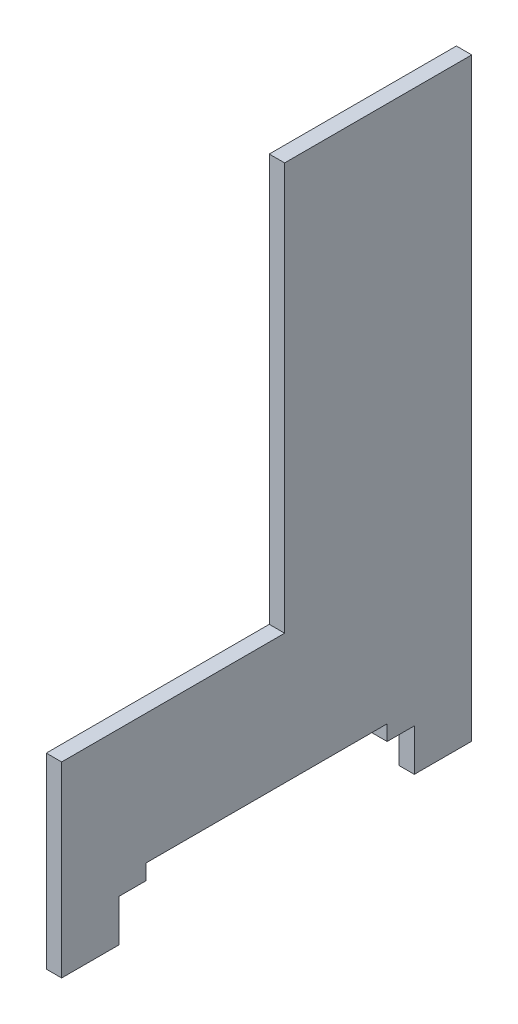
from build123d import *

# Parameters (mm, degrees)
BOSS_EXTRUDE1_DEPTH = 3


with BuildPart() as part:
    # Sketch4 → Boss-Extrude1 (new body)
    with BuildSketch(Plane(origin=(-40, 0, 0), x_dir=(0, 0, -1), z_dir=(1, 0, 0))):
        Polygon((40, 119.507009142), (40, 3.55), (28.8, 3.55), (28.8, 11.75), (23.5, 11.75), (23.5, 14.75), (-23.5, 14.75), (-23.5, 11.75), (-28.8, 11.75), (-28.8, 3.55), (-40, 3.55), (-40, 40.05), (3.5, 40.05), (3.5, 119.507009142), align=None)
    extrude(amount=BOSS_EXTRUDE1_DEPTH)


solid = part.part
